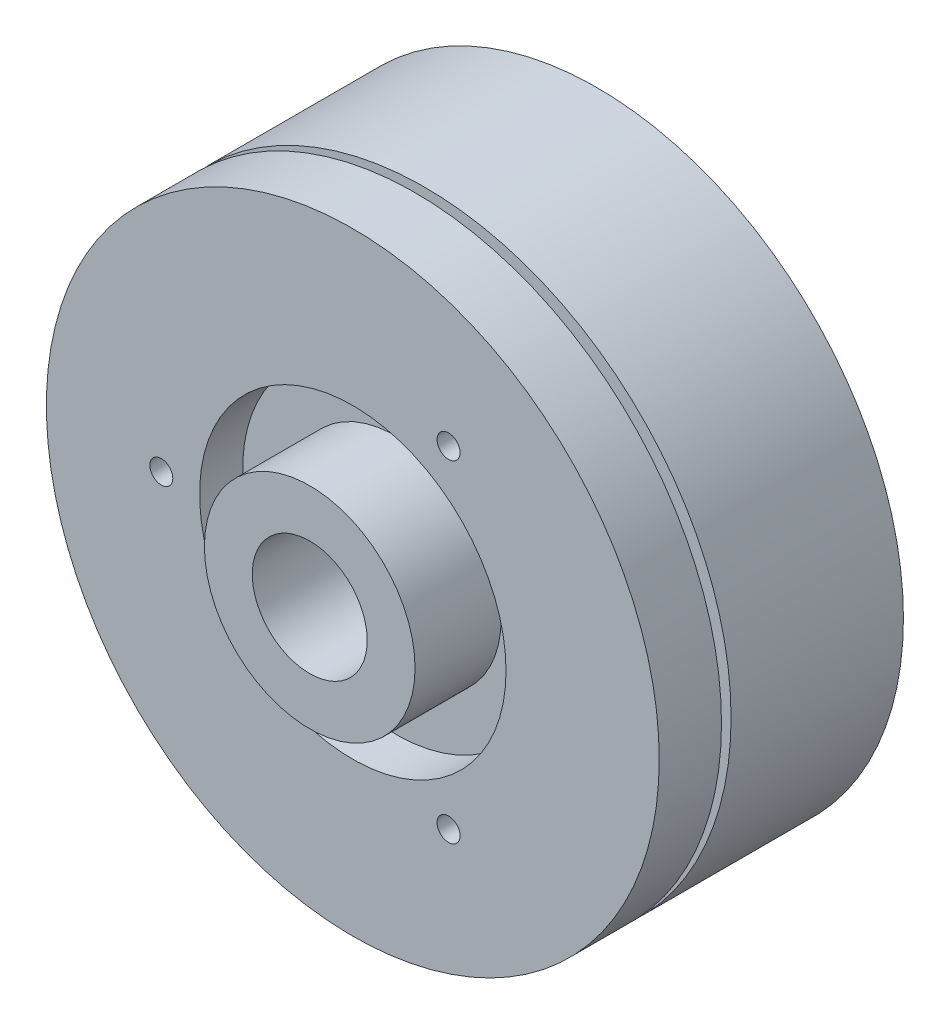
from build123d import *

# Parameters (mm, degrees)
SKETCH_1_R          = 16
EXTRUDE_1_DEPTH     = 9
SKETCH_2_R          = 6
EXTRUDE_2_DEPTH     = 0.5
SKETCH_3_R          = 16
EXTRUDE_3_DEPTH     = 3.25
SKETCH_4_R          = 5.5
EXTRUDE_4_DEPTH     = 2.25
SKETCH_5_R          = 3
CUT_EXTRUDE_1_DEPTH = 26.25
SKETCH_6_R          = 8
SKETCH_6_R_2        = 5.5
CUT_EXTRUDE_2_DEPTH = 2.25
SKETCH_7_R          = 0.6
CUT_EXTRUDE_3_DEPTH = 6
SKETCH_8_R          = 0.6
CUT_EXTRUDE_4_DEPTH = 3


with BuildPart() as part:
    # 草图1 → 凸台-拉伸1 (new body)
    with BuildSketch(Plane.XY):
        Circle(SKETCH_1_R)
    extrude(amount=EXTRUDE_1_DEPTH)

    # 草图2 → 凸台-拉伸2 (add)
    with BuildSketch(Plane.XY.offset(9)):
        Circle(SKETCH_2_R)
    extrude(amount=EXTRUDE_2_DEPTH)

    # 草图3 → 凸台-拉伸3 (add)
    with BuildSketch(Plane.XY.offset(9.5)):
        Circle(SKETCH_3_R)
    extrude(amount=EXTRUDE_3_DEPTH)

    # 草图4 → 凸台-拉伸4 (add)
    with BuildSketch(Plane.XY.offset(12.75)):
        Circle(SKETCH_4_R)
    extrude(amount=EXTRUDE_4_DEPTH)

    # 草图5 → 切除-拉伸1 (cut)
    with BuildSketch(Plane.XY.offset(15)):
        Circle(SKETCH_5_R)
    extrude(amount=-CUT_EXTRUDE_1_DEPTH, mode=Mode.SUBTRACT)

    # 草图6 → 切除-拉伸2 (cut)
    with BuildSketch(Plane.XY.offset(12.75)):
        Circle(SKETCH_6_R)
        Circle(SKETCH_6_R_2, mode=Mode.SUBTRACT)
    extrude(amount=-CUT_EXTRUDE_2_DEPTH, mode=Mode.SUBTRACT)

    # 草图7 → 切除-拉伸3 (cut)
    with BuildSketch(Plane(origin=(0, 0, 0), x_dir=(-1, 0, 0), z_dir=(0, 0, -1))):
        with Locations((8.660254038, 5)):
            Circle(SKETCH_7_R)
        with Locations((-8.660254038, 5)):
            Circle(SKETCH_7_R)
        with Locations((0, -10)):
            Circle(SKETCH_7_R)
    extrude(amount=-CUT_EXTRUDE_3_DEPTH, mode=Mode.SUBTRACT)

    # 草图8 → 切除-拉伸4 (cut)
    with BuildSketch(Plane.XY.offset(12.75)):
        with Locations((5, -8.660254038)):
            Circle(SKETCH_8_R)
        with Locations((5, 8.660254038)):
            Circle(SKETCH_8_R)
        with Locations((-10, 0)):
            Circle(SKETCH_8_R)
    extrude(amount=-CUT_EXTRUDE_4_DEPTH, mode=Mode.SUBTRACT)


solid = part.part
